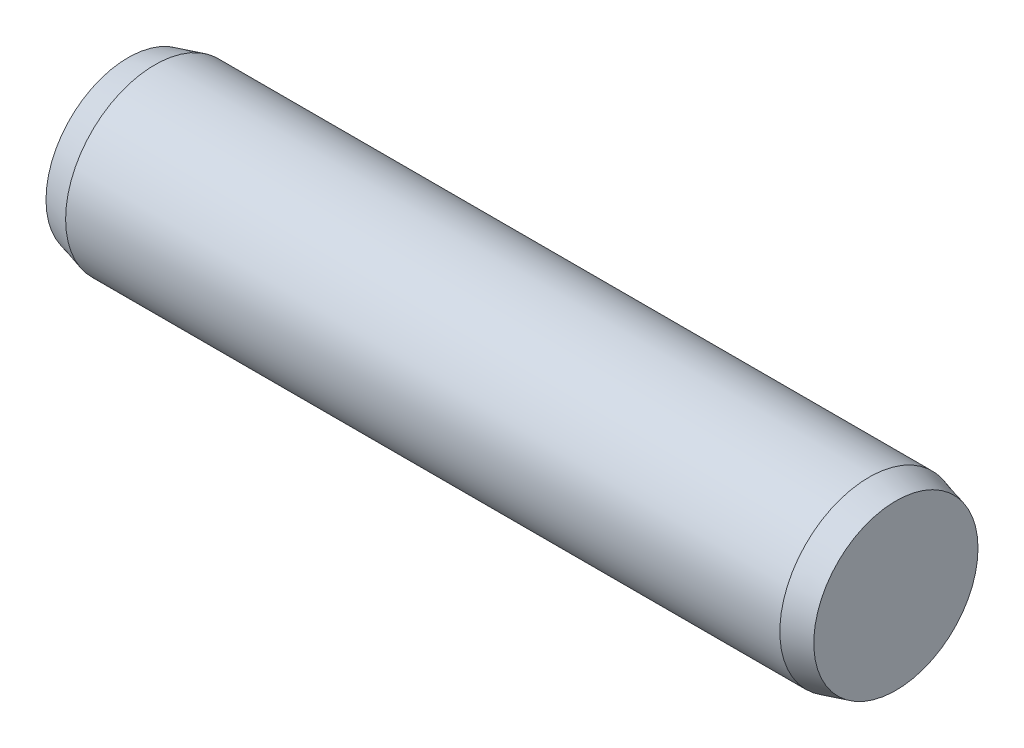
from build123d import *

# Parameters (mm, degrees)
SKETCH2_R           = 2
EXTRUDE1_DEPTH      = 8
EXTRUDE1_DEPTH_BACK = 8
SKETCH3_R           = 2
EXTRUDE2_DEPTH      = 0.6
EXTRUDE2_TAPER      = 15
SKETCH4_R           = 2
EXTRUDE3_DEPTH      = 0.6
EXTRUDE3_TAPER      = 15


with BuildPart() as part:
    # Sketch2 → Extrude1 (new body, two sides)
    with BuildSketch(Plane(origin=(0, 0, 0), x_dir=(0, 0, -1), z_dir=(1, 0, 0))) as extrude1_sk:
        Circle(SKETCH2_R)
    extrude(amount=EXTRUDE1_DEPTH)
    extrude(extrude1_sk.sketch, amount=-EXTRUDE1_DEPTH_BACK)

    # Sketch3 → Extrude2 (add)
    with BuildSketch(Plane(origin=(8, 0, 0), x_dir=(0, 0, -1), z_dir=(1, 0, 0))):
        Circle(SKETCH3_R)
    extrude(amount=EXTRUDE2_DEPTH, taper=EXTRUDE2_TAPER)

    # Sketch4 → Extrude3 (add)
    with BuildSketch(Plane.ZY.offset(8)):
        Circle(SKETCH4_R)
    extrude(amount=EXTRUDE3_DEPTH, taper=EXTRUDE3_TAPER)


solid = part.part
